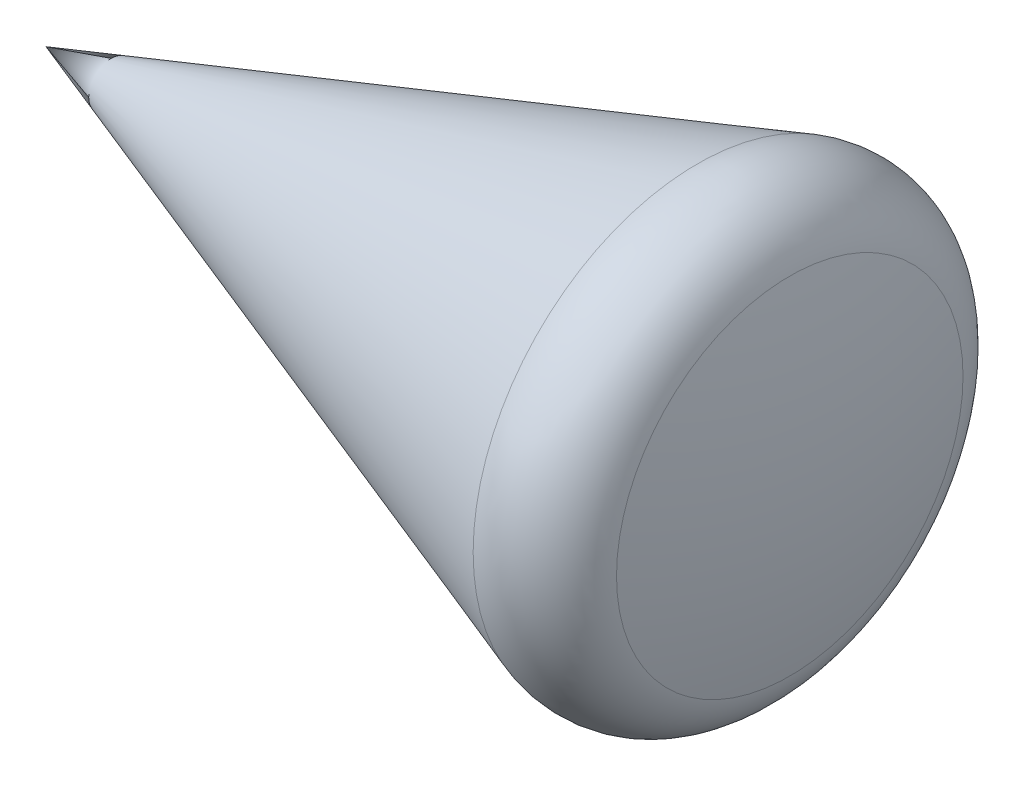
from build123d import *


with BuildPart() as part:
    # Sketch1 → Revolve1 (revolve)
    with BuildSketch(Plane(origin=(0, 0, 0), x_dir=(1, 0, 0), z_dir=(0, 1, 0))):
        with BuildLine():
            Line((0, 0), (6450, 0))
            ThreePointArc((6450, 0), (6407.814319225, 736.488730626), (6281.80910067, 1463.343576451))
            ThreePointArc((6281.80910067, 1463.343576451), (5987.822189921, 1852.277407363), (5502.11387305, 1894.529737955))
            Line((5502.11387305, 1894.529737955), (0, 0))
        make_face()
    revolve(axis=Axis((0, 0, 0), (1, 0, 0)))


solid = part.part
